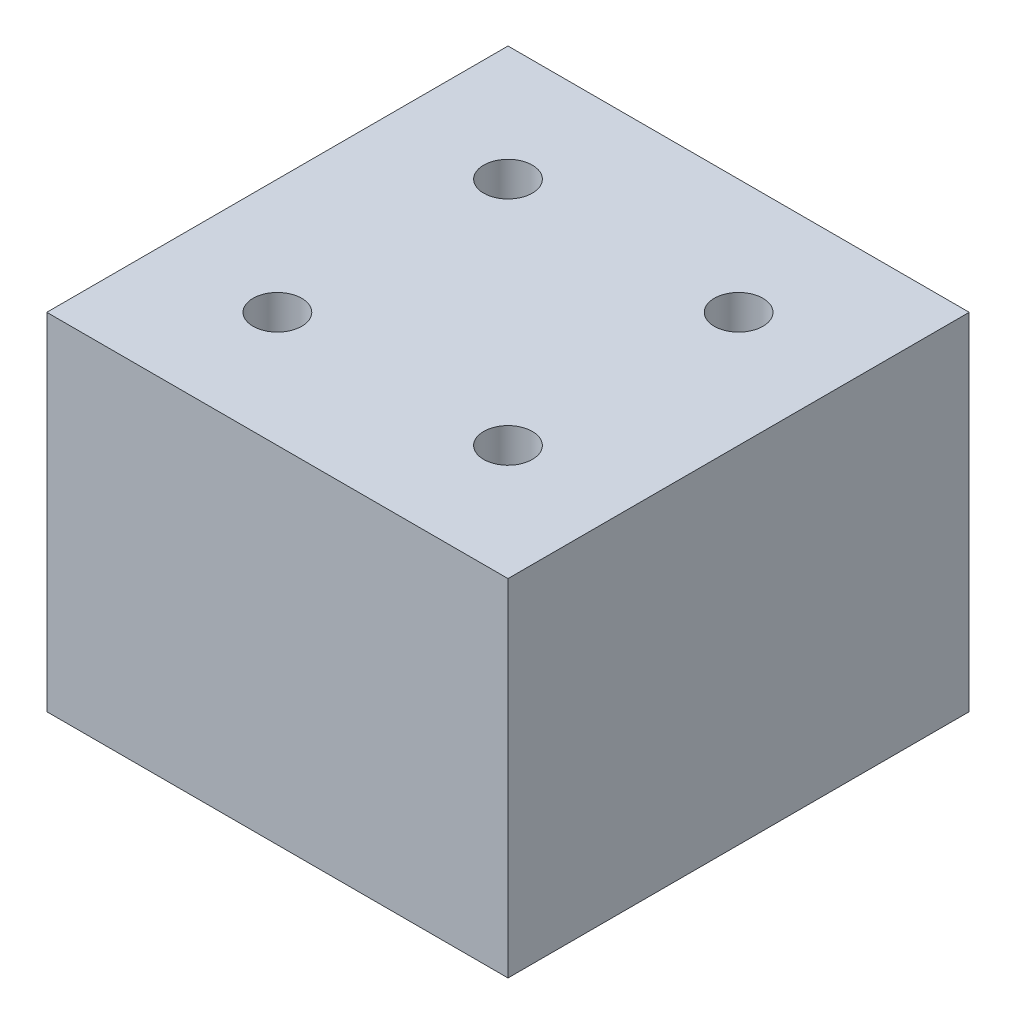
from build123d import *

# Parameters (mm, degrees)
SKETCH2_W                   = 101.6
SKETCH2_H                   = 101.6
BOSS_EXTRUDE1_DEPTH         = 76.2
F_1_2_13_TAPPED_HOLE4_D     = 10.71626
F_1_2_13_TAPPED_HOLE4_DEPTH = 35.052
F_1_2_13_TAPPED_HOLE4_TIP   = 3.219489309


with BuildPart() as part:
    # Sketch2 → Boss-Extrude1 (new body)
    with BuildSketch(Plane(origin=(0, 0, 0), x_dir=(1, 0, 0), z_dir=(0, 1, 0))):
        with Locations((50.8, 50.8)):
            Rectangle(SKETCH2_W, SKETCH2_H)
    extrude(amount=BOSS_EXTRUDE1_DEPTH)

    # 1/2-13 Tapped Hole4
    with Locations(Plane(origin=(25.4, 76.2, -25.4), x_dir=(0, 0, 1), z_dir=(0, 1, 0))):
        with Locations((0, 0), (-50.8, 0), (-50.8, 50.8), (0, 50.8)):
            Hole(F_1_2_13_TAPPED_HOLE4_D / 2, depth=F_1_2_13_TAPPED_HOLE4_DEPTH)
            with Locations((0, 0, -(F_1_2_13_TAPPED_HOLE4_DEPTH + F_1_2_13_TAPPED_HOLE4_TIP / 2))):  # 118° drill point
                Cone(0, F_1_2_13_TAPPED_HOLE4_D / 2, F_1_2_13_TAPPED_HOLE4_TIP, mode=Mode.SUBTRACT)


solid = part.part
